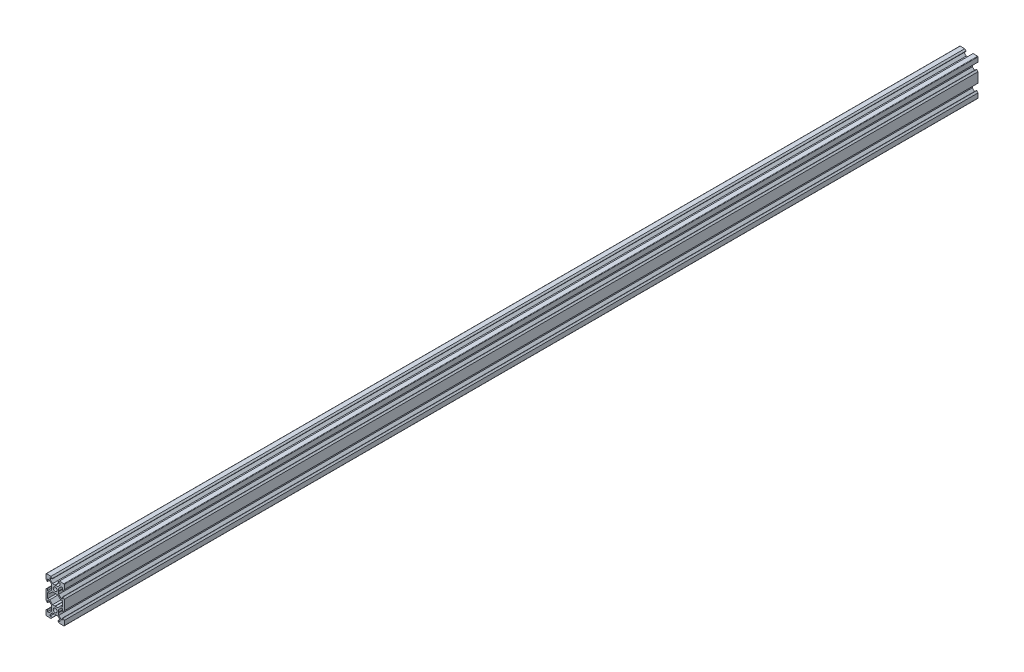
from build123d import *

# Parameters (mm, degrees)
SKETCH1_R           = 2.1
BOSS_EXTRUDE1_DEPTH = 500
FILLET1_R           = 0.5


with BuildPart() as part:
    # Sketch1 → Boss-Extrude1 (new body, symmetric)
    with BuildSketch(Plane.XY):
        Polygon((2.839339828, 13.9), (5.5, 16.560660172), (5.5, 18.2), (3.125, 18.2), (3.125, 18.545), (4.58, 20), (10, 20), (10, 14.58), (8.545, 13.125), (8.2, 13.125), (8.2, 15.5), (6.560660172, 15.5), (3.9, 12.839339828), (3.9, 10.2), (3.7, 10), (3.9, 9.8), (3.9, 7.160660172), (6.560660172, 4.5), (8.2, 4.5), (8.2, 6.875), (8.545, 6.875), (10, 5.42), (10, -5.42), (8.545, -6.875), (8.2, -6.875), (8.2, -4.5), (6.560660172, -4.5), (3.9, -7.160660172), (3.9, -9.8), (3.7, -10), (3.9, -10.2), (3.9, -12.839339828), (6.560660172, -15.5), (8.2, -15.5), (8.2, -13.125), (8.545, -13.125), (10, -14.58), (10, -20), (4.58, -20), (3.125, -18.545), (3.125, -18.2), (5.5, -18.2), (5.5, -16.560660172), (2.839339828, -13.9), (0.2, -13.9), (0, -13.7), (-0.2, -13.9), (-2.839339828, -13.9), (-5.5, -16.560660172), (-5.5, -18.2), (-3.125, -18.2), (-3.125, -18.545), (-4.58, -20), (-10, -20), (-10, -14.58), (-8.545, -13.125), (-8.2, -13.125), (-8.2, -15.5), (-6.560660172, -15.5), (-3.9, -12.839339828), (-3.9, -10.2), (-3.7, -10), (-3.9, -9.8), (-3.9, -7.160660172), (-6.560660172, -4.5), (-8.2, -4.5), (-8.2, -6.875), (-8.545, -6.875), (-10, -5.42), (-10, 5.42), (-8.545, 6.875), (-8.2, 6.875), (-8.2, 4.5), (-6.560660172, 4.5), (-3.9, 7.160660172), (-3.9, 9.8), (-3.7, 10), (-3.9, 10.2), (-3.9, 12.839339828), (-6.560660172, 15.5), (-8.2, 15.5), (-8.2, 13.125), (-8.545, 13.125), (-10, 14.58), (-10, 20), (-4.58, 20), (-3.125, 18.545), (-3.125, 18.2), (-5.5, 18.2), (-5.5, 16.560660172), (-2.839339828, 13.9), (-0.2, 13.9), (0, 13.7), (0.2, 13.9), align=None)
        with Locations((0, 10)):
            Circle(SKETCH1_R, mode=Mode.SUBTRACT)
        with Locations((0, -10)):
            Circle(SKETCH1_R, mode=Mode.SUBTRACT)
        Polygon((8.2, -3), (8.2, 3), (5.939339828, 3), (2.839339828, 6.1), (0.2, 6.1), (0, 6.3), (-0.2, 6.1), (-2.839339828, 6.1), (-5.939339828, 3), (-8.2, 3), (-8.2, -3), (-5.939339828, -3), (-2.839339828, -6.1), (-0.2, -6.1), (0, -6.3), (0.2, -6.1), (2.839339828, -6.1), (5.939339828, -3), align=None, mode=Mode.SUBTRACT)
    extrude(amount=BOSS_EXTRUDE1_DEPTH, both=True)

    # Fillet1
    fillet1_edges = [part.edges().sort_by_distance(p)[0] for p in [
        (10, -20, 0),
        (-10, -20, 0),
        (-10, 20, 0),
        (10, 20, 0),
    ]]
    fillet(fillet1_edges, radius=FILLET1_R)


solid = part.part
